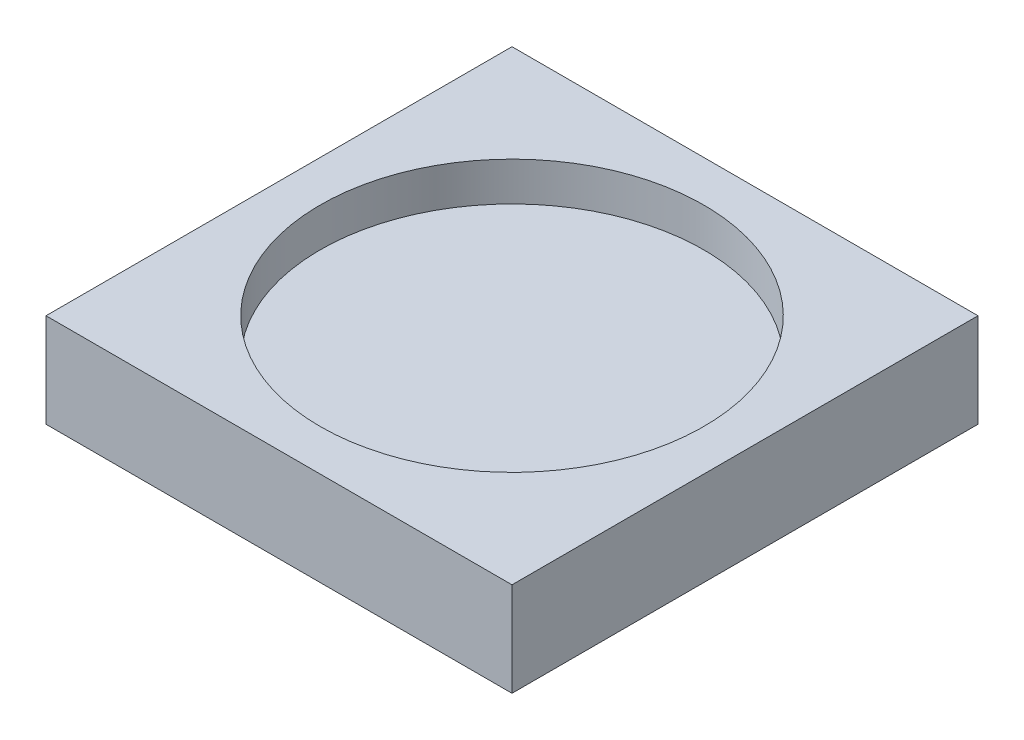
from build123d import *

# Parameters (mm, degrees)
SKETCH1_W           = 152.4
SKETCH1_H           = 152.4
BOSS_EXTRUDE1_DEPTH = 30.734
SKETCH2_R           = 62.738
CUT_EXTRUDE1_DEPTH  = 12.7


with BuildPart() as part:
    # Sketch1 → Boss-Extrude1 (new body)
    with BuildSketch(Plane(origin=(0, 0, 0), x_dir=(1, 0, 0), z_dir=(0, 1, 0))):
        with Locations((76.2, 76.2)):
            Rectangle(SKETCH1_W, SKETCH1_H)
    extrude(amount=BOSS_EXTRUDE1_DEPTH)

    # Sketch2 → Cut-Extrude1 (cut)
    with BuildSketch(Plane(origin=(0, 30.734, 0), x_dir=(1, 0, 0), z_dir=(0, 1, 0))):
        with Locations((76.2, 76.2)):
            Circle(SKETCH2_R)
    extrude(amount=-CUT_EXTRUDE1_DEPTH, mode=Mode.SUBTRACT)


solid = part.part
